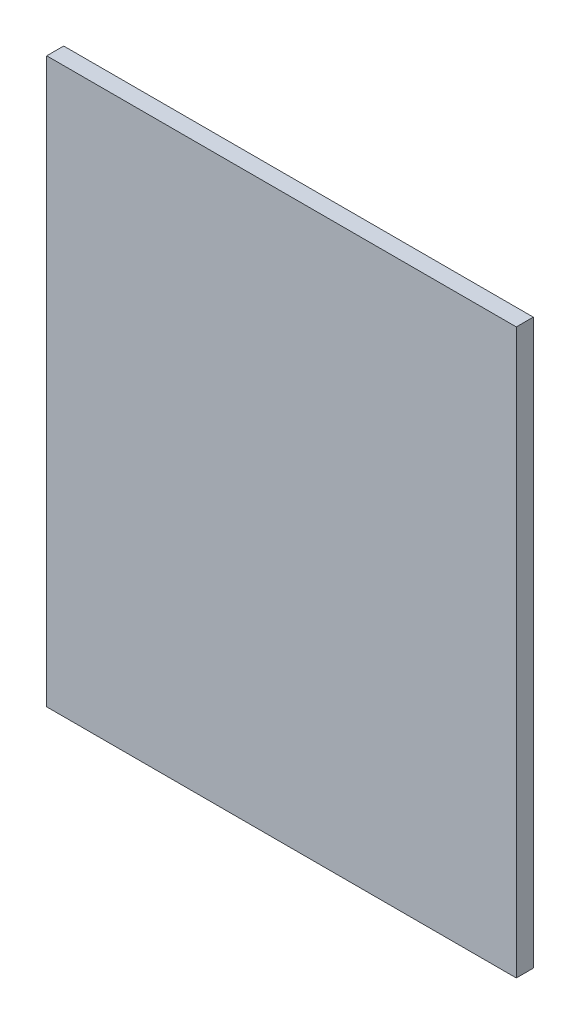
from build123d import *

# Parameters (mm, degrees)
SKETCH1_W           = 498
SKETCH1_H           = 598
BOSS_EXTRUDE1_DEPTH = 18


with BuildPart() as part:
    # Sketch1 → Boss-Extrude1 (new body)
    with BuildSketch(Plane.XY):
        Rectangle(SKETCH1_W, SKETCH1_H)
    extrude(amount=BOSS_EXTRUDE1_DEPTH)


solid = part.part
